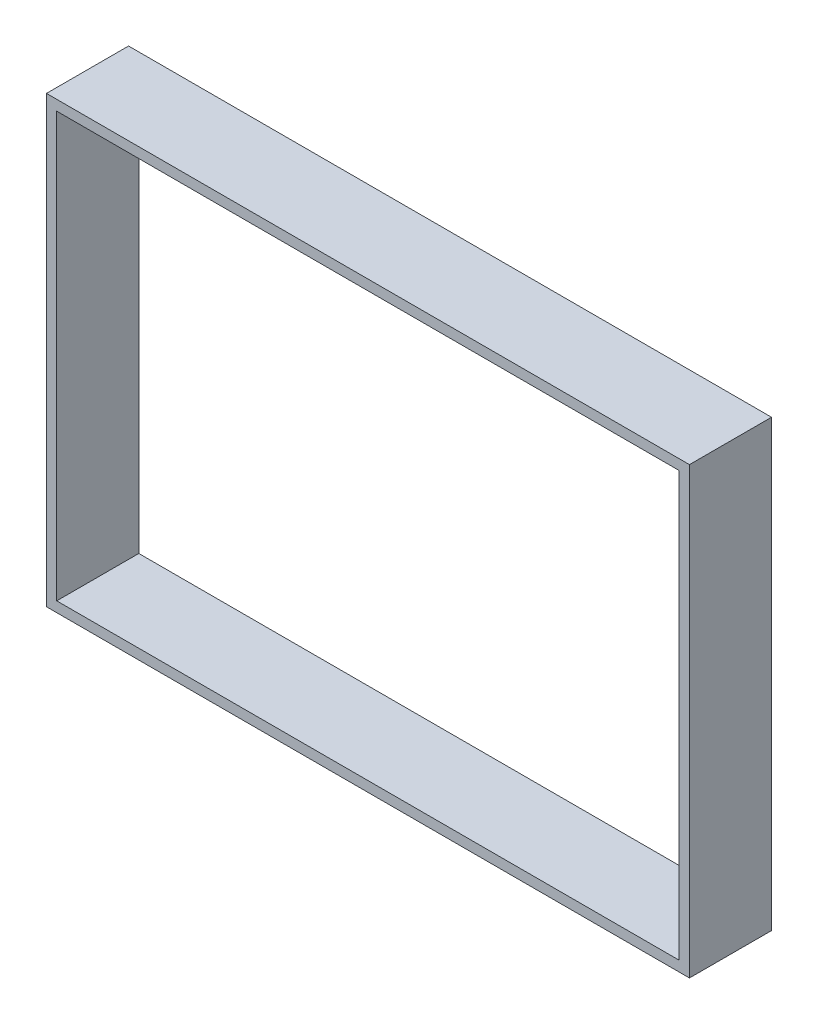
from build123d import *

# Parameters (mm, degrees)
SKETCH1_W       = 94
SKETCH1_H       = 65
SKETCH1_W_2     = 91
SKETCH1_H_2     = 62
TOP_WALLS_DEPTH = 12


with BuildPart() as part:
    # Sketch1 → Top Walls (new body)
    with BuildSketch(Plane.XY):
        Rectangle(SKETCH1_W, SKETCH1_H)
        Rectangle(SKETCH1_W_2, SKETCH1_H_2, mode=Mode.SUBTRACT)
    extrude(amount=TOP_WALLS_DEPTH)


solid = part.part
